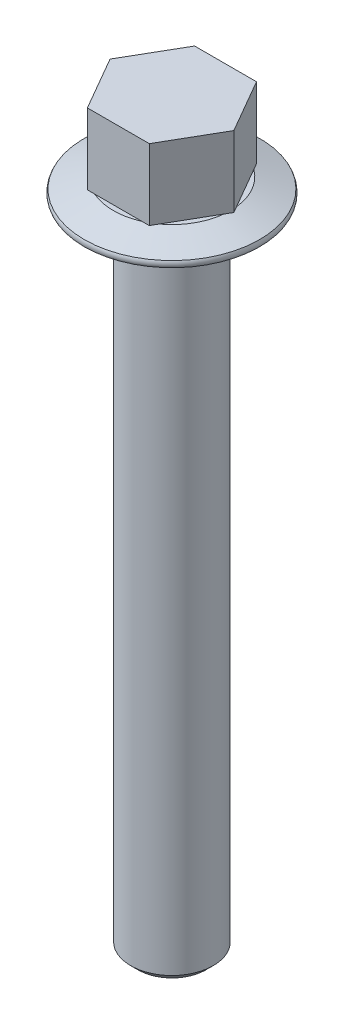
from build123d import *

# Parameters (mm, degrees)
BOSS_EXTRUDE1_DEPTH = 6.88
SKETCH3_R           = 4
BOSS_EXTRUDE2_DEPTH = 64
SKETCH4_R           = 4
CUT_EXTRUDE1_DEPTH  = 0.7
CUT_EXTRUDE1_TAPER  = -45
CHAMFER1_SIZE       = 0.7


with BuildPart() as part:
    # Sketch1 → Revolve1 (revolve)
    with BuildSketch(Plane.XY):
        with BuildLine():
            Line((0, 0), (8.5, 0))
            ThreePointArc((8.5, 0), (8.580384758, 0.3), (8.5, 0.6))
            Line((8.5, 0.6), (5.680922138, 1.62606043))
            Line((5.680922138, 1.62606043), (0, 1.62606043))
            Line((0, 1.62606043), (0, 0))
        make_face()
    revolve(axis=Axis((0, 1.62606043, 0), (0, -1, 0)))

    # Sketch2 → Boss-Extrude1 (add)
    with BuildSketch(Plane(origin=(0, 1.62606043, 0), x_dir=(1, 0, 0), z_dir=(0, 1, 0))):
        Polygon((6, 0), (3, 5.196152423), (-3, 5.196152423), (-6, 0), (-3, -5.196152423), (3, -5.196152423), align=None)
    extrude(amount=BOSS_EXTRUDE1_DEPTH)

    # Sketch3 → Boss-Extrude2 (add)
    with BuildSketch(Plane.XZ):
        Circle(SKETCH3_R)
    extrude(amount=BOSS_EXTRUDE2_DEPTH)

    # Sketch4 → Cut-Extrude1 (cut)
    with BuildSketch(Plane.XZ.offset(64)):
        Circle(SKETCH4_R)
    extrude(amount=-CUT_EXTRUDE1_DEPTH, taper=CUT_EXTRUDE1_TAPER, mode=Mode.SUBTRACT)

    # Chamfer1
    chamfer1_edges = [part.edges().sort_by_distance(p)[0] for p in [
        (-4, -63.3, 0),
    ]]
    chamfer(chamfer1_edges, length=CHAMFER1_SIZE)


solid = part.part
